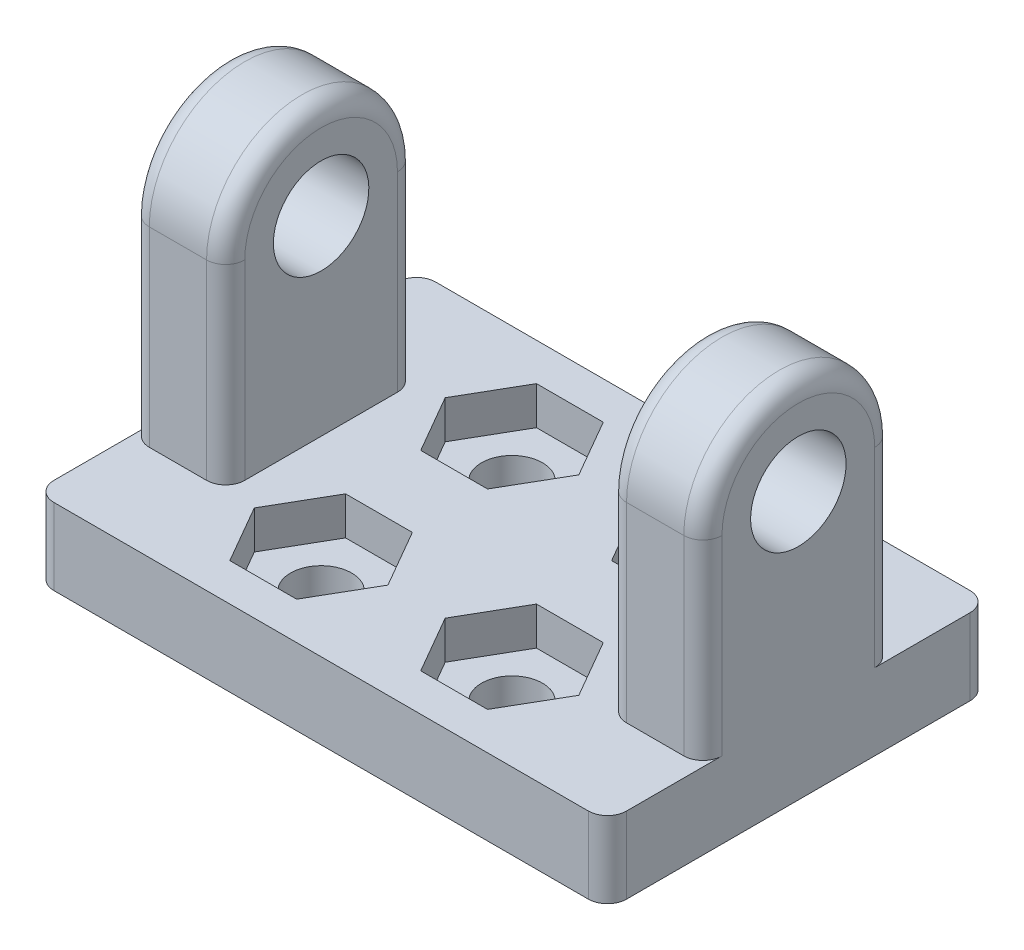
from build123d import *

# Parameters (mm, degrees)
ESQUISSE2_R                  = 2.5
BOSS_EXTRU_1_DEPTH           = 15
ESQUISSE4_W                  = 30
ESQUISSE4_H                  = 20
BOSS_EXTRU_2_DEPTH           = 4
ENL_V_MAT_EXTRU_1_REACH      = 6
ESQUISSE5_R                  = 1.6
ESQUISSE6_W                  = 20
ESQUISSE6_H                  = 21.543710407
ENL_V_MAT_EXTRU_2_DEPTH      = 16
ENL_V_MAT_EXTRU_3_DEPTH      = 16
ENL_V_MAT_EXTRU_3_DEPTH_BACK = 2
CONG_1_R                     = 1


with BuildPart() as part:
    # Esquisse2 → Boss.-Extru.1 (new body, symmetric)
    with BuildSketch(Plane(origin=(0, 0, 0), x_dir=(0, 0, -1), z_dir=(1, 0, 0))):
        with BuildLine():
            Line((5, 0), (5, -10))
            Line((5, -10), (-5, -10))
            Line((-5, -10), (-5, 0))
            ThreePointArc((-5, 0), (0, 5), (5, 0))
        make_face()
        Circle(ESQUISSE2_R, mode=Mode.SUBTRACT)
    extrude(amount=BOSS_EXTRU_1_DEPTH, both=True)

    # Esquisse4 → Boss.-Extru.2 (add)
    with BuildSketch(Plane.XZ.offset(10)):
        Rectangle(ESQUISSE4_W, ESQUISSE4_H)
    extrude(amount=BOSS_EXTRU_2_DEPTH)

    # Esquisse5 → Enlèv. mat.-Extru.1 (cut, up to next)
    with BuildSketch(Plane(origin=(0, -10, 0), x_dir=(1, 0, 0), z_dir=(0, 1, 0)), mode=Mode.PRIVATE) as enl_v_mat_extru_1_sk1:
        with Locations(Location((5, -5, 0), (0, 0, 270))):  # turned: the seam where the file's is
            Circle(ESQUISSE5_R)
    enl_v_mat_extru_1_tool1 = extrude(enl_v_mat_extru_1_sk1.sketch, amount=-ENL_V_MAT_EXTRU_1_REACH, mode=Mode.PRIVATE) & part.part
    add(enl_v_mat_extru_1_tool1.solids().sort_by_distance((5, -10, 5))[0], mode=Mode.SUBTRACT)
    # Esquisse5 → Enlèv. mat.-Extru.1 (cut, up to next)
    with BuildSketch(Plane(origin=(0, -10, 0), x_dir=(1, 0, 0), z_dir=(0, 1, 0)), mode=Mode.PRIVATE) as enl_v_mat_extru_1_sk2:
        with Locations(Location((5, 5, 0), (0, 0, 270))):  # turned: the seam where the file's is
            Circle(ESQUISSE5_R)
    enl_v_mat_extru_1_tool2 = extrude(enl_v_mat_extru_1_sk2.sketch, amount=-ENL_V_MAT_EXTRU_1_REACH, mode=Mode.PRIVATE) & part.part
    add(enl_v_mat_extru_1_tool2.solids().sort_by_distance((5, -10, -5))[0], mode=Mode.SUBTRACT)
    # Esquisse5 → Enlèv. mat.-Extru.1 (cut, up to next)
    with BuildSketch(Plane(origin=(0, -10, 0), x_dir=(1, 0, 0), z_dir=(0, 1, 0)), mode=Mode.PRIVATE) as enl_v_mat_extru_1_sk3:
        with Locations(Location((-5, 5, 0), (0, 0, 270))):  # turned: the seam where the file's is
            Circle(ESQUISSE5_R)
    enl_v_mat_extru_1_tool3 = extrude(enl_v_mat_extru_1_sk3.sketch, amount=-ENL_V_MAT_EXTRU_1_REACH, mode=Mode.PRIVATE) & part.part
    add(enl_v_mat_extru_1_tool3.solids().sort_by_distance((-5, -10, -5))[0], mode=Mode.SUBTRACT)
    # Esquisse5 → Enlèv. mat.-Extru.1 (cut, up to next)
    with BuildSketch(Plane(origin=(0, -10, 0), x_dir=(1, 0, 0), z_dir=(0, 1, 0)), mode=Mode.PRIVATE) as enl_v_mat_extru_1_sk4:
        with Locations(Location((-5, -5, 0), (0, 0, 270))):  # turned: the seam where the file's is
            Circle(ESQUISSE5_R)
    enl_v_mat_extru_1_tool4 = extrude(enl_v_mat_extru_1_sk4.sketch, amount=-ENL_V_MAT_EXTRU_1_REACH, mode=Mode.PRIVATE) & part.part
    add(enl_v_mat_extru_1_tool4.solids().sort_by_distance((-5, -10, 5))[0], mode=Mode.SUBTRACT)

    # Esquisse6 → Enlèv. mat.-Extru.2 (cut, through all)
    with BuildSketch(Plane.XY.offset(5)):
        with Locations((0, 0.771855204)):
            Rectangle(ESQUISSE6_W, ESQUISSE6_H)
    extrude(amount=-ENL_V_MAT_EXTRU_2_DEPTH, mode=Mode.SUBTRACT)

    # Esquisse7 → Enlèv. mat.-Extru.3 (cut, two sides)
    with BuildSketch(Plane(origin=(0, -10, 0), x_dir=(1, 0, 0), z_dir=(0, 1, 0))) as enl_v_mat_extru_3_sk:
        Polygon((-1.5, -5), (-3.25, -1.968911087), (-6.75, -1.968911087), (-8.5, -5), (-6.75, -8.031088913), (-3.25, -8.031088913), align=None)
        Polygon((8.5, -5), (6.75, -1.968911087), (3.25, -1.968911087), (1.5, -5), (3.25, -8.031088913), (6.75, -8.031088913), align=None)
        Polygon((8.5, 5), (6.75, 8.031088913), (3.25, 8.031088913), (1.5, 5), (3.25, 1.968911087), (6.75, 1.968911087), align=None)
        Polygon((-1.5, 5), (-3.25, 8.031088913), (-6.75, 8.031088913), (-8.5, 5), (-6.75, 1.968911087), (-3.25, 1.968911087), align=None)
    extrude(amount=ENL_V_MAT_EXTRU_3_DEPTH, mode=Mode.SUBTRACT)
    extrude(enl_v_mat_extru_3_sk.sketch, amount=-ENL_V_MAT_EXTRU_3_DEPTH_BACK, mode=Mode.SUBTRACT)

    # Congé1
    cong_1_edges = [part.edges().sort_by_distance(p)[0] for p in [
        (15, -5, -5),
        (-15, -12, 10),
        (-15, -12, -10),
        (15, -12, -10),
        (15, -12, 10),
        (15, 5, 0),
        (-15, -5, -5),
        (-15, -5, 5),
        (-15, 5, 0),
        (-10, 5, 0),
        (-10, -5, -5),
        (10, -5, -5),
        (10, 5, 0),
        (10, -5, 5),
        (-10, -5, 5),
        (15, -5, 5),
    ]]
    fillet(cong_1_edges, radius=CONG_1_R)


solid = part.part
